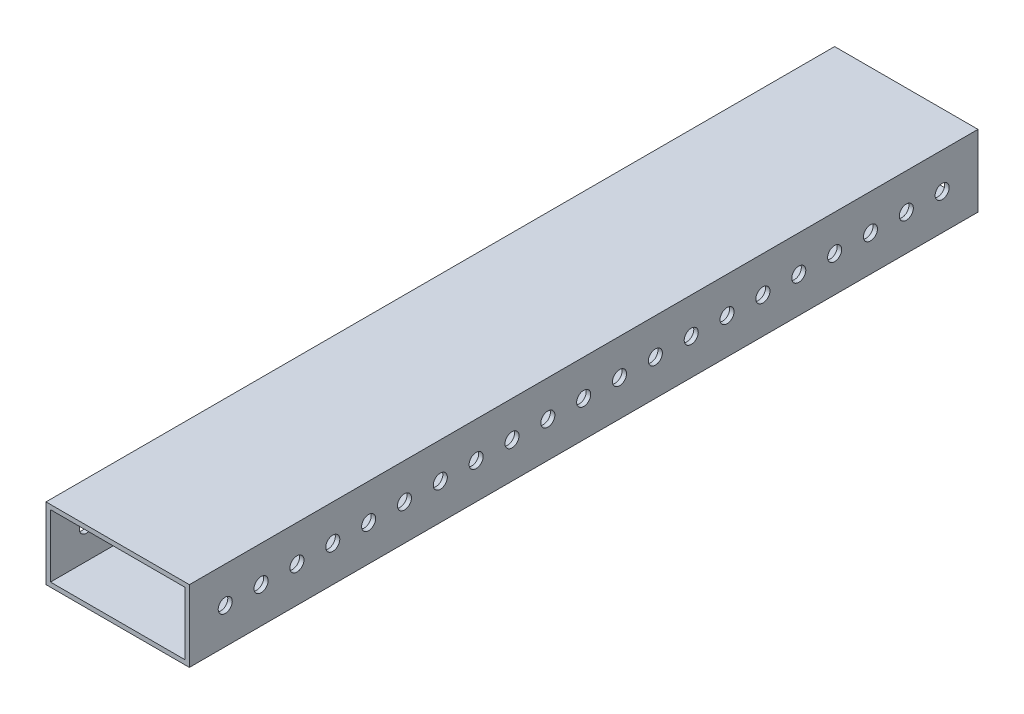
from build123d import *

# Parameters (mm, degrees)
SKETCH1_W           = 50.8
SKETCH1_H           = 25.4
SKETCH1_W_2         = 47.625
SKETCH1_H_2         = 22.225
BOSS_EXTRUDE1_DEPTH = 279.4
SKETCH2_R           = 2.4892
CUT_EXTRUDE1_DEPTH  = 51.8


with BuildPart() as part:
    # Sketch1 → Boss-Extrude1 (new body)
    with BuildSketch(Plane.XY):
        with Locations((25.4, 12.7)):
            Rectangle(SKETCH1_W, SKETCH1_H)
        with Locations((25.4, 12.7)):
            Rectangle(SKETCH1_W_2, SKETCH1_H_2, mode=Mode.SUBTRACT)
    extrude(amount=BOSS_EXTRUDE1_DEPTH)

    # Sketch2 → Cut-Extrude1 (cut, through all)
    with BuildSketch(Plane(origin=(50.8, 0, 0), x_dir=(0, 0, -1), z_dir=(1, 0, 0))):
        with Locations((-266.7, 12.7)):
            Circle(SKETCH2_R)
        with Locations((-254, 12.7)):
            Circle(SKETCH2_R)
        with Locations((-241.3, 12.7)):
            Circle(SKETCH2_R)
        with Locations((-228.6, 12.7)):
            Circle(SKETCH2_R)
        with Locations((-215.9, 12.7)):
            Circle(SKETCH2_R)
        with Locations((-203.2, 12.7)):
            Circle(SKETCH2_R)
        with Locations((-190.5, 12.7)):
            Circle(SKETCH2_R)
        with Locations((-177.8, 12.7)):
            Circle(SKETCH2_R)
        with Locations((-165.1, 12.7)):
            Circle(SKETCH2_R)
        with Locations((-152.4, 12.7)):
            Circle(SKETCH2_R)
        with Locations((-139.7, 12.7)):
            Circle(SKETCH2_R)
        with Locations((-127, 12.7)):
            Circle(SKETCH2_R)
        with Locations((-114.3, 12.7)):
            Circle(SKETCH2_R)
        with Locations((-101.6, 12.7)):
            Circle(SKETCH2_R)
        with Locations((-88.9, 12.7)):
            Circle(SKETCH2_R)
        with Locations((-76.2, 12.7)):
            Circle(SKETCH2_R)
        with Locations((-63.5, 12.7)):
            Circle(SKETCH2_R)
        with Locations((-50.8, 12.7)):
            Circle(SKETCH2_R)
        with Locations((-38.1, 12.7)):
            Circle(SKETCH2_R)
        with Locations((-25.4, 12.7)):
            Circle(SKETCH2_R)
        with Locations((-12.7, 12.7)):
            Circle(SKETCH2_R)
    extrude(amount=-CUT_EXTRUDE1_DEPTH, mode=Mode.SUBTRACT)


solid = part.part
